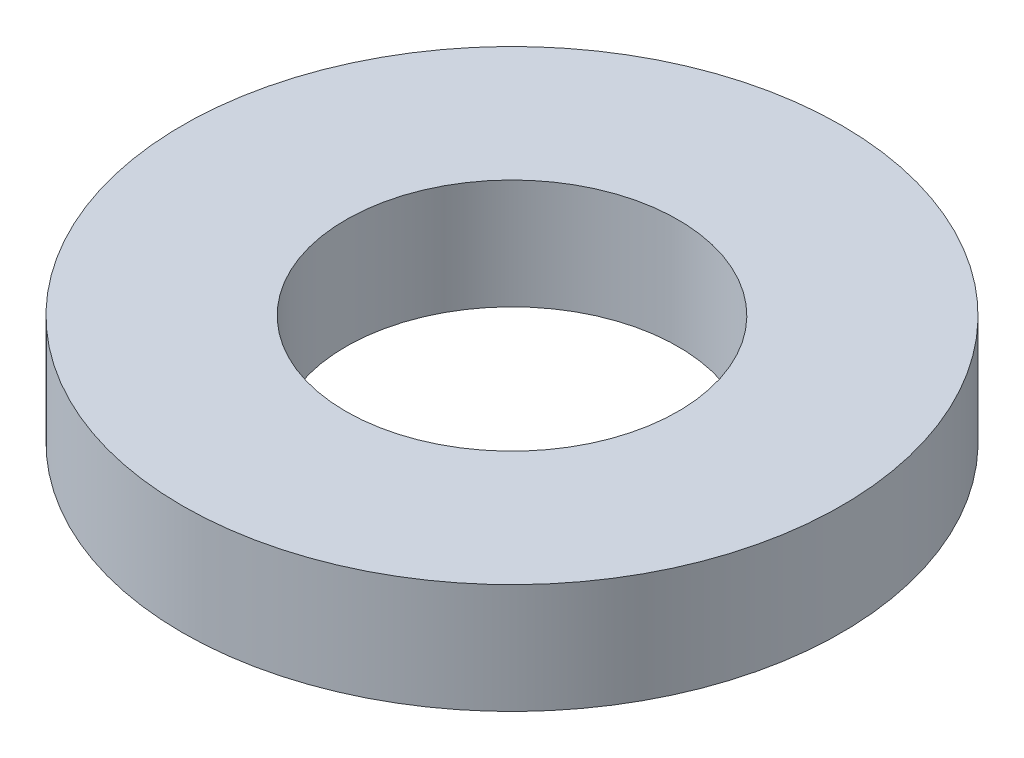
from build123d import *

# Parameters (mm, degrees)
SKETCH1_R           = 2.38125
BOSS_EXTRUDE1_DEPTH = 0.79375
CLEARANCE_HOLE1_D   = 2.4


with BuildPart() as part:
    # Sketch1 → Boss-Extrude1 (new body)
    with BuildSketch(Plane(origin=(0, 0, 0), x_dir=(1, 0, 0), z_dir=(0, 1, 0))):
        Circle(SKETCH1_R)
    extrude(amount=BOSS_EXTRUDE1_DEPTH)

    # Clearance Hole1 (through all)
    with Locations(Plane(origin=(0, 0.79375, 0), x_dir=(1, 0, 0), z_dir=(0, 1, 0))):
        with Locations((0, 0)):
            Hole(CLEARANCE_HOLE1_D / 2)


solid = part.part
